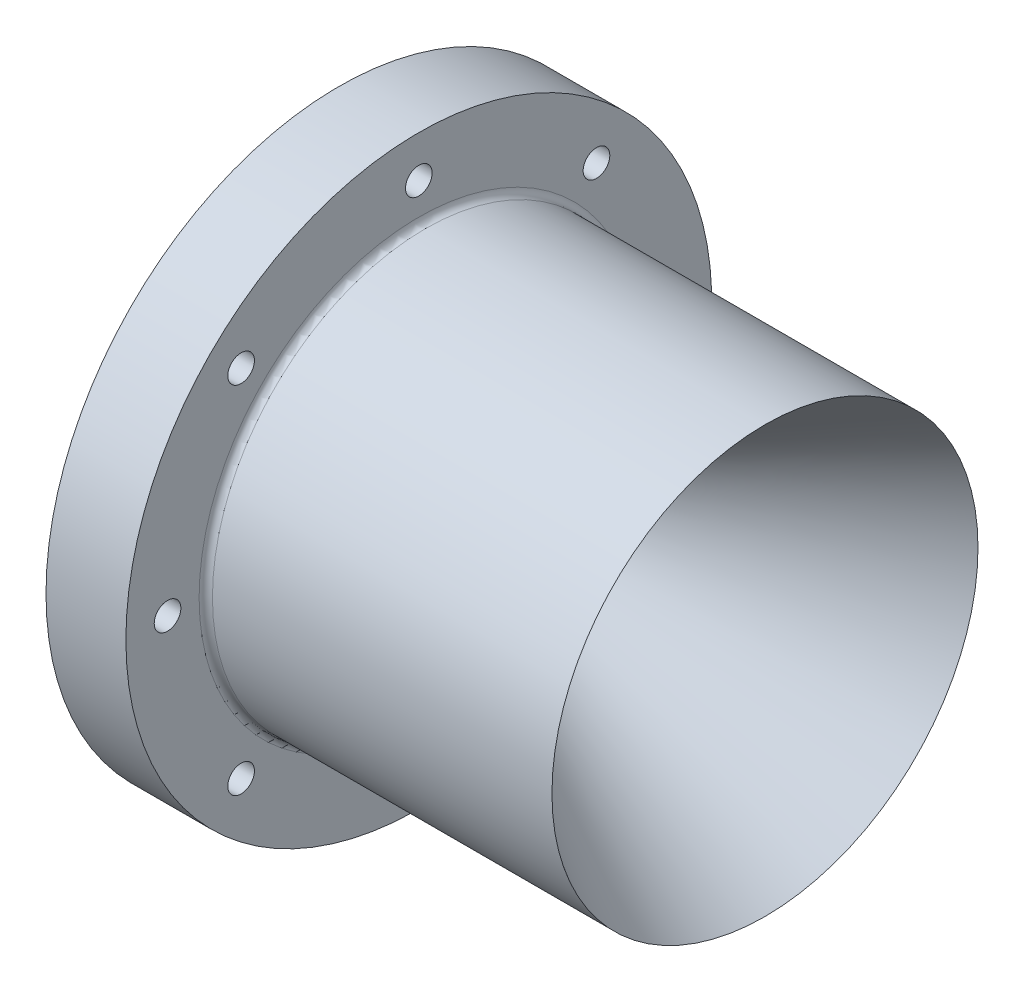
from build123d import *

# Parameters (mm, degrees)
CUT_EXTRUDE2_REACH = 103.6
SKETCH3_R          = 3.175
FILLET1_R          = 3.175
FILLET2_R          = 1.5875


with BuildPart() as part:
    # Sketch1 → Revolve1 (revolve)
    with BuildSketch(Plane.XY):
        Polygon((-12.7, 9.525), (-30.109602918, 39.679316793), (-30.109602918, 50.8), (-30.109602918, 69.85), (-11.059602918, 69.85), (-11.059602918, 50.8), (71.490397082, 50.8), (0, 9.525), align=None)
    revolve(axis=Axis((0, 0, 0), (1, 0, 0)))

    # Sketch3 → Cut-Extrude2 (cut, up to next)
    with BuildSketch(Plane.ZY.offset(30.109602918), mode=Mode.PRIVATE) as cut_extrude2_sk1:
        with Locations((0, 59.9186)):
            Circle(SKETCH3_R)
    cut_extrude2_tool1 = extrude(cut_extrude2_sk1.sketch, amount=-CUT_EXTRUDE2_REACH, mode=Mode.PRIVATE) & part.part
    add(cut_extrude2_tool1.solids().sort_by_distance((-30.109603, 59.9186, 0))[0], mode=Mode.SUBTRACT)
    # Sketch3 → Cut-Extrude2 (cut, up to next)
    with BuildSketch(Plane.ZY.offset(30.109602918), mode=Mode.PRIVATE) as cut_extrude2_sk2:
        with Locations((42.368848379, 42.368848379)):
            Circle(SKETCH3_R)
    cut_extrude2_tool2 = extrude(cut_extrude2_sk2.sketch, amount=-CUT_EXTRUDE2_REACH, mode=Mode.PRIVATE) & part.part
    add(cut_extrude2_tool2.solids().sort_by_distance((-30.109603, 42.368848, 42.368848))[0], mode=Mode.SUBTRACT)
    # Sketch3 → Cut-Extrude2 (cut, up to next)
    with BuildSketch(Plane.ZY.offset(30.109602918), mode=Mode.PRIVATE) as cut_extrude2_sk3:
        with Locations((59.9186, 0)):
            Circle(SKETCH3_R)
    cut_extrude2_tool3 = extrude(cut_extrude2_sk3.sketch, amount=-CUT_EXTRUDE2_REACH, mode=Mode.PRIVATE) & part.part
    add(cut_extrude2_tool3.solids().sort_by_distance((-30.109603, 0, 59.9186))[0], mode=Mode.SUBTRACT)
    # Sketch3 → Cut-Extrude2 (cut, up to next)
    with BuildSketch(Plane.ZY.offset(30.109602918), mode=Mode.PRIVATE) as cut_extrude2_sk4:
        with Locations((42.368848379, -42.368848379)):
            Circle(SKETCH3_R)
    cut_extrude2_tool4 = extrude(cut_extrude2_sk4.sketch, amount=-CUT_EXTRUDE2_REACH, mode=Mode.PRIVATE) & part.part
    add(cut_extrude2_tool4.solids().sort_by_distance((-30.109603, -42.368848, 42.368848))[0], mode=Mode.SUBTRACT)
    # Sketch3 → Cut-Extrude2 (cut, up to next)
    with BuildSketch(Plane.ZY.offset(30.109602918), mode=Mode.PRIVATE) as cut_extrude2_sk5:
        with Locations((0, -59.9186)):
            Circle(SKETCH3_R)
    cut_extrude2_tool5 = extrude(cut_extrude2_sk5.sketch, amount=-CUT_EXTRUDE2_REACH, mode=Mode.PRIVATE) & part.part
    add(cut_extrude2_tool5.solids().sort_by_distance((-30.109603, -59.9186, 0))[0], mode=Mode.SUBTRACT)
    # Sketch3 → Cut-Extrude2 (cut, up to next)
    with BuildSketch(Plane.ZY.offset(30.109602918), mode=Mode.PRIVATE) as cut_extrude2_sk6:
        with Locations((-42.368848379, -42.368848379)):
            Circle(SKETCH3_R)
    cut_extrude2_tool6 = extrude(cut_extrude2_sk6.sketch, amount=-CUT_EXTRUDE2_REACH, mode=Mode.PRIVATE) & part.part
    add(cut_extrude2_tool6.solids().sort_by_distance((-30.109603, -42.368848, -42.368848))[0], mode=Mode.SUBTRACT)
    # Sketch3 → Cut-Extrude2 (cut, up to next)
    with BuildSketch(Plane.ZY.offset(30.109602918), mode=Mode.PRIVATE) as cut_extrude2_sk7:
        with Locations((-59.9186, 0)):
            Circle(SKETCH3_R)
    cut_extrude2_tool7 = extrude(cut_extrude2_sk7.sketch, amount=-CUT_EXTRUDE2_REACH, mode=Mode.PRIVATE) & part.part
    add(cut_extrude2_tool7.solids().sort_by_distance((-30.109603, 0, -59.9186))[0], mode=Mode.SUBTRACT)
    # Sketch3 → Cut-Extrude2 (cut, up to next)
    with BuildSketch(Plane.ZY.offset(30.109602918), mode=Mode.PRIVATE) as cut_extrude2_sk8:
        with Locations((-42.368848379, 42.368848379)):
            Circle(SKETCH3_R)
    cut_extrude2_tool8 = extrude(cut_extrude2_sk8.sketch, amount=-CUT_EXTRUDE2_REACH, mode=Mode.PRIVATE) & part.part
    add(cut_extrude2_tool8.solids().sort_by_distance((-30.109603, 42.368848, -42.368848))[0], mode=Mode.SUBTRACT)

    # Fillet1
    fillet1_edges = [part.edges().sort_by_distance(p)[0] for p in [
        (0, -9.525, 0),
        (-12.7, -9.525, 0),
    ]]
    fillet(fillet1_edges, radius=FILLET1_R)

    # Fillet2
    fillet2_edges = [part.edges().sort_by_distance(p)[0] for p in [
        (-11.059602918, -50.8, 0),
    ]]
    fillet(fillet2_edges, radius=FILLET2_R)


solid = part.part
